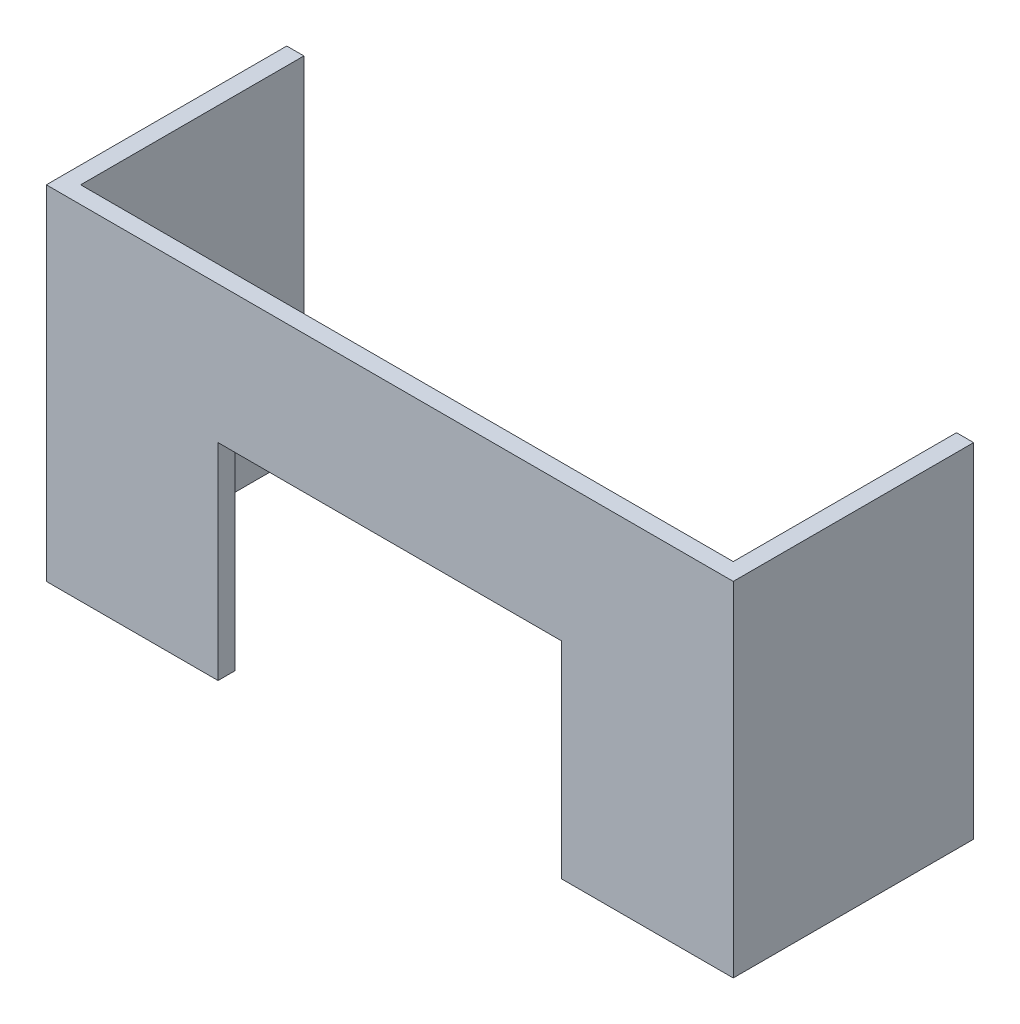
from build123d import *

# Parameters (mm, degrees)
SKETCH1_W           = 400
SKETCH1_H           = 150
BOSS_EXTRUDE1_DEPTH = 200
SKETCH2_W           = 380
SKETCH2_H           = 130
CUT_EXTRUDE1_DEPTH  = 200
SKETCH3_W           = 200
SKETCH3_H           = 120
CUT_EXTRUDE2_DEPTH  = 20
SKETCH4_W           = 400
SKETCH4_H           = 200
CUT_EXTRUDE3_DEPTH  = 10


with BuildPart() as part:
    # Sketch1 → Boss-Extrude1 (new body)
    with BuildSketch(Plane(origin=(0, 0, 0), x_dir=(1, 0, 0), z_dir=(0, 1, 0))):
        Rectangle(SKETCH1_W, SKETCH1_H)
    extrude(amount=BOSS_EXTRUDE1_DEPTH)

    # Sketch2 → Cut-Extrude1 (cut)
    with BuildSketch(Plane(origin=(0, 200, 0), x_dir=(1, 0, 0), z_dir=(0, 1, 0))):
        Rectangle(SKETCH2_W, SKETCH2_H)
    extrude(amount=-CUT_EXTRUDE1_DEPTH, mode=Mode.SUBTRACT)

    # Sketch3 → Cut-Extrude2 (cut)
    with BuildSketch(Plane.XY.offset(75)):
        with Locations((0, 60)):
            Rectangle(SKETCH3_W, SKETCH3_H)
    extrude(amount=-CUT_EXTRUDE2_DEPTH, mode=Mode.SUBTRACT)

    # Sketch4 → Cut-Extrude3 (cut)
    with BuildSketch(Plane(origin=(0, 0, -75), x_dir=(-1, 0, 0), z_dir=(0, 0, -1))):
        with Locations((0, 100)):
            Rectangle(SKETCH4_W, SKETCH4_H)
    extrude(amount=-CUT_EXTRUDE3_DEPTH, mode=Mode.SUBTRACT)


solid = part.part
